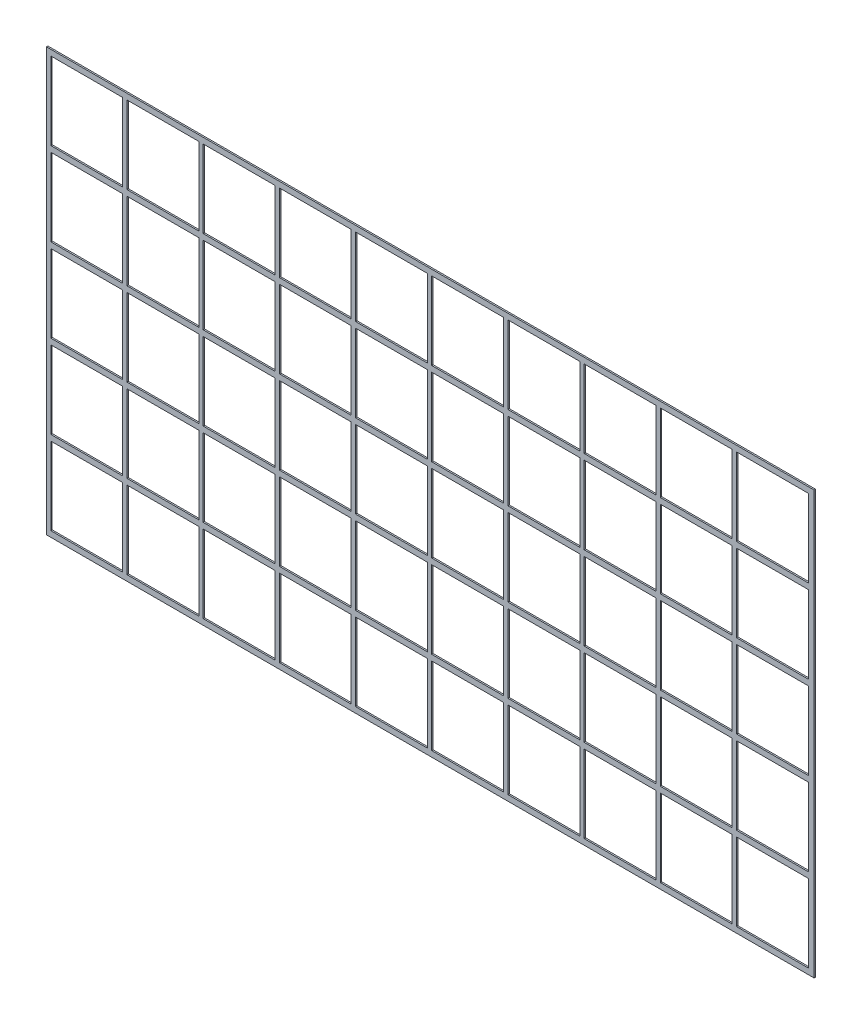
from build123d import *

# Parameters (mm, degrees)
SKETCH1_W           = 1695.45
SKETCH1_H           = 933.45
BOSS_EXTRUDE1_DEPTH = 3.175
SKETCH2_W           = 158.75
SKETCH2_H           = 171.45
CUT_EXTRUDE1_DEPTH  = 4.175


with BuildPart() as part:
    # Sketch1 → Boss-Extrude1 (new body)
    with BuildSketch(Plane.XY):
        Rectangle(SKETCH1_W, SKETCH1_H)
    extrude(amount=BOSS_EXTRUDE1_DEPTH)

    # Sketch2 → Cut-Extrude1 (cut, through all)
    with BuildSketch(Plane.XY.offset(3.175)):
        with Locations((-758.825, 368.3)):
            Rectangle(SKETCH2_W, SKETCH2_H)
        with Locations((-590.55, 368.3)):
            Rectangle(SKETCH2_W, SKETCH2_H)
        with Locations((-422.275, 368.3)):
            Rectangle(SKETCH2_W, SKETCH2_H)
        with Locations((-254, 368.3)):
            Rectangle(SKETCH2_W, SKETCH2_H)
        with Locations((-85.725, 368.3)):
            Rectangle(SKETCH2_W, SKETCH2_H)
        with Locations((82.55, 368.3)):
            Rectangle(SKETCH2_W, SKETCH2_H)
        with Locations((250.825, 368.3)):
            Rectangle(SKETCH2_W, SKETCH2_H)
        with Locations((419.1, 368.3)):
            Rectangle(SKETCH2_W, SKETCH2_H)
        with Locations((587.375, 368.3)):
            Rectangle(SKETCH2_W, SKETCH2_H)
        with Locations((755.65, 368.3)):
            Rectangle(SKETCH2_W, SKETCH2_H)
        with Locations((-590.55, 184.15)):
            Rectangle(SKETCH2_W, SKETCH2_H)
        with Locations((-422.275, 184.15)):
            Rectangle(SKETCH2_W, SKETCH2_H)
        with Locations((-254, 184.15)):
            Rectangle(SKETCH2_W, SKETCH2_H)
        with Locations((-85.725, 184.15)):
            Rectangle(SKETCH2_W, SKETCH2_H)
        with Locations((82.55, 184.15)):
            Rectangle(SKETCH2_W, SKETCH2_H)
        with Locations((250.825, 184.15)):
            Rectangle(SKETCH2_W, SKETCH2_H)
        with Locations((419.1, 184.15)):
            Rectangle(SKETCH2_W, SKETCH2_H)
        with Locations((587.375, 184.15)):
            Rectangle(SKETCH2_W, SKETCH2_H)
        with Locations((755.65, 184.15)):
            Rectangle(SKETCH2_W, SKETCH2_H)
        with Locations((-590.55, 0)):
            Rectangle(SKETCH2_W, SKETCH2_H)
        with Locations((-422.275, 0)):
            Rectangle(SKETCH2_W, SKETCH2_H)
        with Locations((-254, 0)):
            Rectangle(SKETCH2_W, SKETCH2_H)
        with Locations((-85.725, 0)):
            Rectangle(SKETCH2_W, SKETCH2_H)
        with Locations((82.55, 0)):
            Rectangle(SKETCH2_W, SKETCH2_H)
        with Locations((250.825, 0)):
            Rectangle(SKETCH2_W, SKETCH2_H)
        with Locations((419.1, 0)):
            Rectangle(SKETCH2_W, SKETCH2_H)
        with Locations((587.375, 0)):
            Rectangle(SKETCH2_W, SKETCH2_H)
        with Locations((755.65, 0)):
            Rectangle(SKETCH2_W, SKETCH2_H)
        with Locations((-590.55, -184.15)):
            Rectangle(SKETCH2_W, SKETCH2_H)
        with Locations((-422.275, -184.15)):
            Rectangle(SKETCH2_W, SKETCH2_H)
        with Locations((-254, -184.15)):
            Rectangle(SKETCH2_W, SKETCH2_H)
        with Locations((-85.725, -184.15)):
            Rectangle(SKETCH2_W, SKETCH2_H)
        with Locations((82.55, -184.15)):
            Rectangle(SKETCH2_W, SKETCH2_H)
        with Locations((250.825, -184.15)):
            Rectangle(SKETCH2_W, SKETCH2_H)
        with Locations((419.1, -184.15)):
            Rectangle(SKETCH2_W, SKETCH2_H)
        with Locations((587.375, -184.15)):
            Rectangle(SKETCH2_W, SKETCH2_H)
        with Locations((755.65, -184.15)):
            Rectangle(SKETCH2_W, SKETCH2_H)
        with Locations((-590.55, -368.3)):
            Rectangle(SKETCH2_W, SKETCH2_H)
        with Locations((-422.275, -368.3)):
            Rectangle(SKETCH2_W, SKETCH2_H)
        with Locations((-254, -368.3)):
            Rectangle(SKETCH2_W, SKETCH2_H)
        with Locations((-85.725, -368.3)):
            Rectangle(SKETCH2_W, SKETCH2_H)
        with Locations((82.55, -368.3)):
            Rectangle(SKETCH2_W, SKETCH2_H)
        with Locations((250.825, -368.3)):
            Rectangle(SKETCH2_W, SKETCH2_H)
        with Locations((419.1, -368.3)):
            Rectangle(SKETCH2_W, SKETCH2_H)
        with Locations((587.375, -368.3)):
            Rectangle(SKETCH2_W, SKETCH2_H)
        with Locations((755.65, -368.3)):
            Rectangle(SKETCH2_W, SKETCH2_H)
        with Locations((-758.825, 184.15)):
            Rectangle(SKETCH2_W, SKETCH2_H)
        with Locations((-758.825, 0)):
            Rectangle(SKETCH2_W, SKETCH2_H)
        with Locations((-758.825, -184.15)):
            Rectangle(SKETCH2_W, SKETCH2_H)
        with Locations((-758.825, -368.3)):
            Rectangle(SKETCH2_W, SKETCH2_H)
    extrude(amount=-CUT_EXTRUDE1_DEPTH, mode=Mode.SUBTRACT)


solid = part.part
